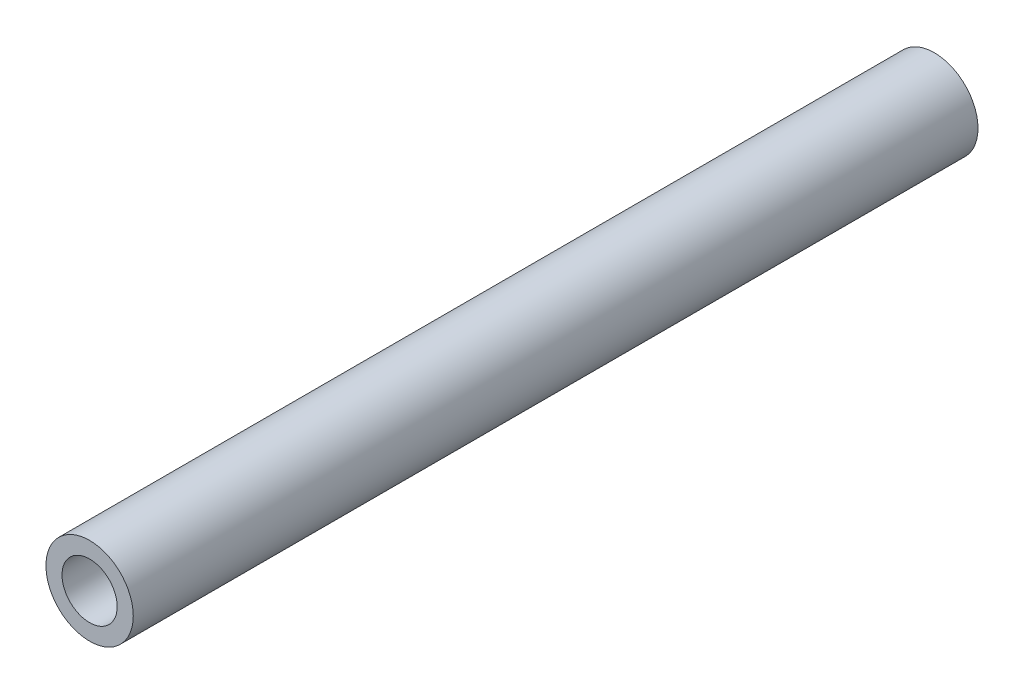
from build123d import *

# Parameters (mm, degrees)
SKETCH1_R           = 24.13
SKETCH1_R_2         = 15.24
BOSS_EXTRUDE1_DEPTH = 233.3625


with BuildPart() as part:
    # Sketch1 → Boss-Extrude1 (new body, symmetric)
    with BuildSketch(Plane.XY):
        Circle(SKETCH1_R)
        Circle(SKETCH1_R_2, mode=Mode.SUBTRACT)
    extrude(amount=BOSS_EXTRUDE1_DEPTH, both=True)


solid = part.part
